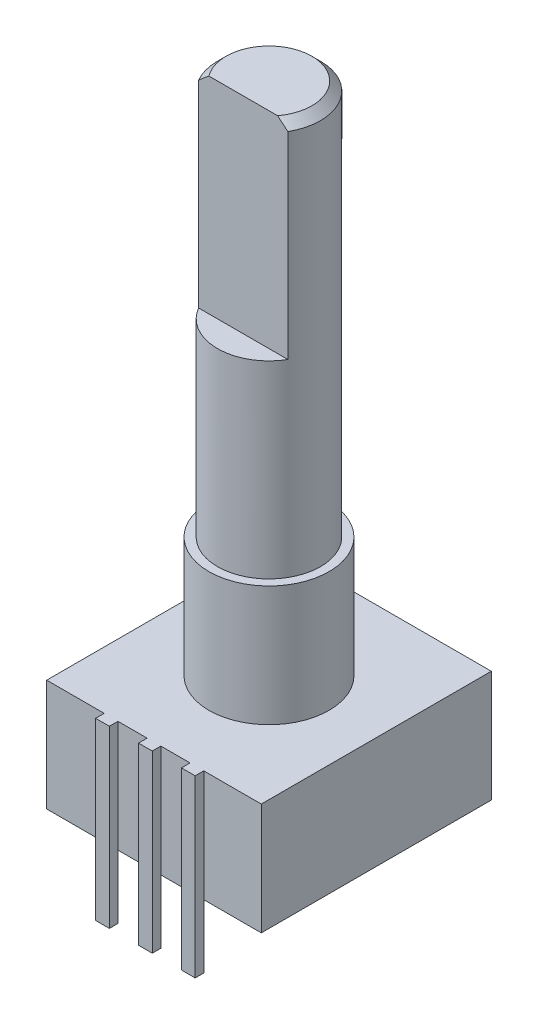
from build123d import *

# Parameters (mm, degrees)
SKETCH1_W           = 12.5
SKETCH1_H           = 13.4
BOSS_EXTRUDE1_DEPTH = 6.5
SKETCH2_R           = 3.5
BOSS_EXTRUDE2_DEPTH = 7
SKETCH3_R           = 3
BOSS_EXTRUDE3_DEPTH = 23
CHAMFER1_SIZE       = 0.5
CUT_EXTRUDE1_DEPTH  = 12
SKETCH5_W           = 0.8
SKETCH5_H           = 10.2
BOSS_EXTRUDE4_DEPTH = 0.5


with BuildPart() as part:
    # Sketch1 → Boss-Extrude1 (new body)
    with BuildSketch(Plane(origin=(0, 0, 0), x_dir=(1, 0, 0), z_dir=(0, 1, 0))):
        Rectangle(SKETCH1_W, SKETCH1_H)
    extrude(amount=-BOSS_EXTRUDE1_DEPTH)

    # Sketch2 → Boss-Extrude2 (add)
    with BuildSketch(Plane(origin=(0, 0, 0), x_dir=(1, 0, 0), z_dir=(0, 1, 0))):
        Circle(SKETCH2_R)
    extrude(amount=BOSS_EXTRUDE2_DEPTH)

    # Sketch3 → Boss-Extrude3 (add)
    with BuildSketch(Plane(origin=(0, 7, 0), x_dir=(1, 0, 0), z_dir=(0, 1, 0))):
        Circle(SKETCH3_R)
    extrude(amount=BOSS_EXTRUDE3_DEPTH)

    # Chamfer1
    chamfer1_edges = [part.edges().sort_by_distance(p)[0] for p in [
        (-3, 30, 0),
    ]]
    chamfer(chamfer1_edges, length=CHAMFER1_SIZE)

    # Sketch4 → Cut-Extrude1 (cut)
    with BuildSketch(Plane(origin=(0, 30, 0), x_dir=(1, 0, 0), z_dir=(0, 1, 0))):
        with BuildLine():
            Line((-2.598076211, -1.5), (2.598076211, -1.5))
            ThreePointArc((2.598076211, -1.5), (0, -3), (-2.598076211, -1.5))
        make_face()
    extrude(amount=-CUT_EXTRUDE1_DEPTH, mode=Mode.SUBTRACT)

    # Sketch5 → Boss-Extrude4 (add)
    with BuildSketch(Plane.XY.offset(6.7)):
        with Locations((-2.5, -5.1)):
            Rectangle(SKETCH5_W, SKETCH5_H)
        with Locations((0, -5.1)):
            Rectangle(SKETCH5_W, SKETCH5_H)
        with Locations((2.5, -5.1)):
            Rectangle(SKETCH5_W, SKETCH5_H)
    extrude(amount=BOSS_EXTRUDE4_DEPTH)


solid = part.part
